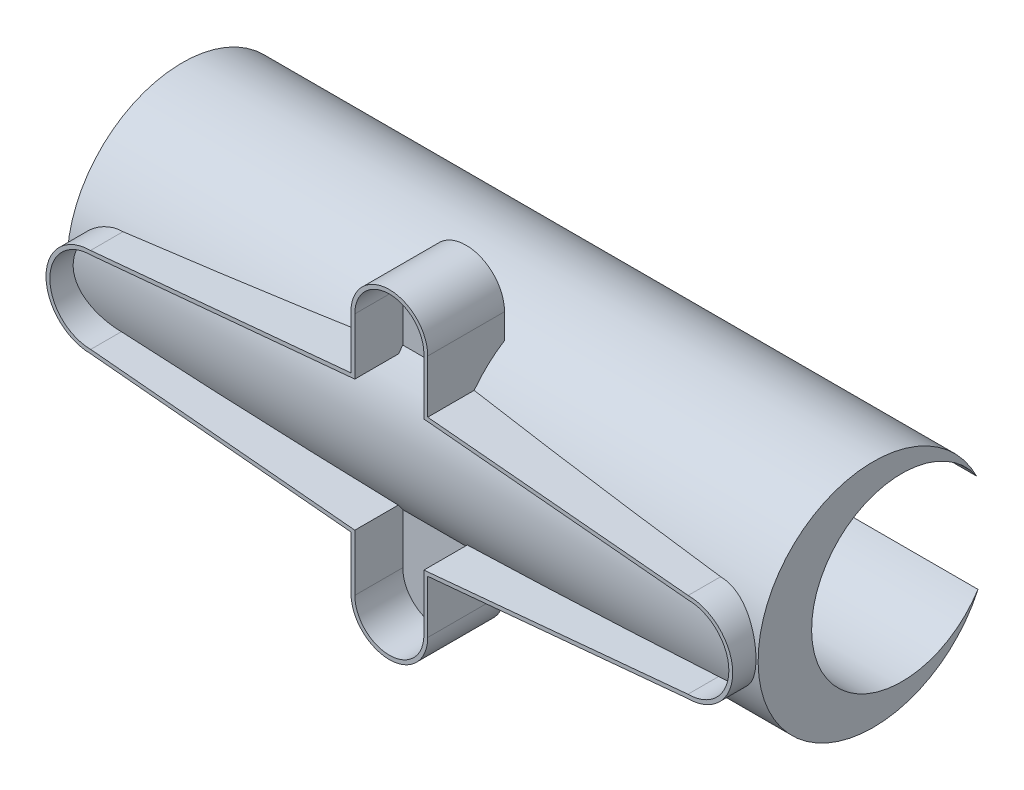
from build123d import *

# Parameters (mm, degrees)
BOSS_EXTRUDE3_DEPTH      = 4
CUT_EXTRUDE1_DEPTH       = 2.5
BOSS_EXTRUDE4_DEPTH      = 16
BOSS_EXTRUDE4_DEPTH_BACK = 20


with BuildPart() as part:
    # Sketch1 → Boss-Extrude3 (new body)
    with BuildSketch(Plane.XY):
        with BuildLine():
            Line((-23.233269255, 11.836996221), (-36.801095313, 10.577126659))
            ThreePointArc((-36.801095313, 10.577126659), (-39.121917966, 8.246850113), (-36.801095313, 5.916573567))
            Line((-36.801095313, 5.916573567), (-23.233269255, 4.656704004))
            Line((-23.233269255, 4.656704004), (-23.233269255, 1.896850113))
            ThreePointArc((-23.233269255, 1.896850113), (-21.233269255, -0.103149887), (-19.233269255, 1.896850113))
            Line((-19.233269255, 1.896850113), (-19.233269255, 4.656704004))
            Line((-19.233269255, 4.656704004), (-5.665443198, 5.916573567))
            ThreePointArc((-5.665443198, 5.916573567), (-3.344620545, 8.246850113), (-5.665443198, 10.577126659))
            Line((-5.665443198, 10.577126659), (-19.233269255, 11.836996221))
            Line((-19.233269255, 11.836996221), (-19.233269255, 14.596850113))
            ThreePointArc((-19.233269255, 14.596850113), (-21.233269255, 16.596850113), (-23.233269255, 14.596850113))
            Line((-23.233269255, 14.596850113), (-23.233269255, 11.836996221))
        make_face()
    extrude(amount=BOSS_EXTRUDE3_DEPTH)

    # Sketch4 → Cut-Extrude1 (cut)
    with BuildSketch(Plane.XY.offset(4)):
        with BuildLine():
            Line((-23.033269255, 11.654707255), (-36.791622165, 10.377145914))
            ThreePointArc((-36.791622165, 10.377145914), (-38.921917966, 8.246850113), (-36.791622165, 6.116554311))
            Line((-36.791622165, 6.116554311), (-23.033269255, 4.83899297))
            Line((-23.033269255, 4.83899297), (-23.033269255, 1.896850113))
            ThreePointArc((-23.033269255, 1.896850113), (-21.233269255, 0.096850113), (-19.433269255, 1.896850113))
            Line((-19.433269255, 1.896850113), (-19.433269255, 4.83899297))
            Line((-19.433269255, 4.83899297), (-5.674916346, 6.116554311))
            ThreePointArc((-5.674916346, 6.116554311), (-3.544620545, 8.246850113), (-5.674916346, 10.377145914))
            Line((-5.674916346, 10.377145914), (-19.433269255, 11.654707255))
            Line((-19.433269255, 11.654707255), (-19.433269255, 14.596850113))
            ThreePointArc((-19.433269255, 14.596850113), (-21.233269255, 16.396850113), (-23.033269255, 14.596850113))
            Line((-23.033269255, 14.596850113), (-23.033269255, 11.654707255))
        make_face()
    extrude(amount=-CUT_EXTRUDE1_DEPTH, mode=Mode.SUBTRACT)

    # Sketch6 → Boss-Extrude4 (add, two sides)
    with BuildSketch(Plane(origin=(-19.233269255, 0, 0), x_dir=(0, 0, -1), z_dir=(1, 0, 0))) as boss_extrude4_sk:
        with BuildLine():
            ThreePointArc((8.595792289, 10.879439419), (0.000480489, 8.183014626), (8.669380496, 5.733470939))
            ThreePointArc((8.669380496, 5.733470939), (-2.786430444, 8.143161335), (8.595792289, 10.879439419))
        make_face()
    extrude(amount=BOSS_EXTRUDE4_DEPTH)
    extrude(boss_extrude4_sk.sketch, amount=-BOSS_EXTRUDE4_DEPTH_BACK)


solid = part.part
